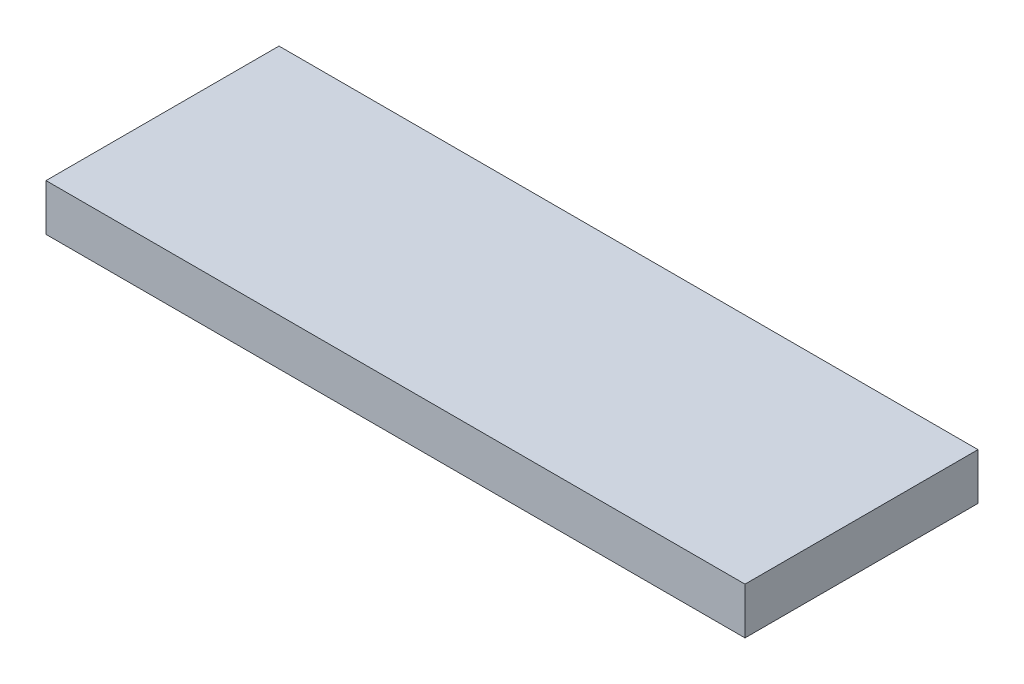
from build123d import *

# Parameters (mm, degrees)
SKETCH1_W           = 150
SKETCH1_H           = 50
BOSS_EXTRUDE1_DEPTH = 10


with BuildPart() as part:
    # Sketch1 → Boss-Extrude1 (new body)
    with BuildSketch(Plane(origin=(0, 0, 0), x_dir=(1, 0, 0), z_dir=(0, 1, 0))):
        Rectangle(SKETCH1_W, SKETCH1_H)
    extrude(amount=BOSS_EXTRUDE1_DEPTH)


solid = part.part
